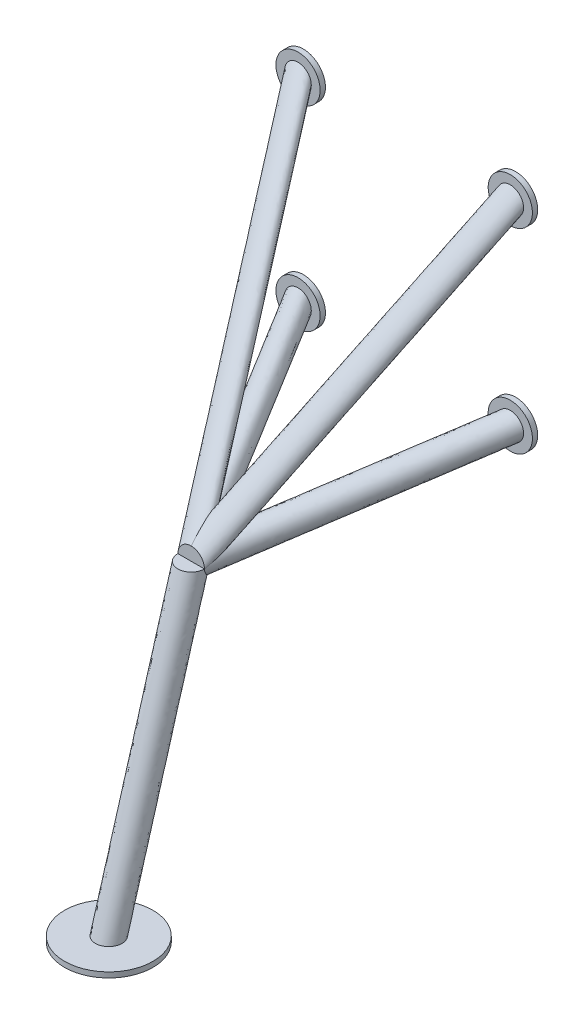
from build123d import *

# Parameters (mm, degrees)
BOSS_EXTRUDE2_START   = -444.5
SKETCH2_R             = 63.5
BOSS_EXTRUDE2_DEPTH   = 7.62
SKETCH1_R             = 31.75
BOSS_EXTRUDE1_DEPTH   = 7.62
BOSS_EXTRUDE1_2_DEPTH = 7.62
BOSS_EXTRUDE1_3_DEPTH = 7.62
BOSS_EXTRUDE1_4_DEPTH = 7.62
SKETCH4_R             = 19.05
SKETCH6_R             = 19.05
SKETCH7_R             = 19.05


with BuildPart() as part:
    # Sketch2 → Boss-Extrude2 (new body)
    with BuildSketch(Plane(origin=(0, 0, 0), x_dir=(1, 0, 0), z_dir=(0, 1, 0)).offset(BOSS_EXTRUDE2_START)):
        with Locations((191.834943245, -431.8)):
            Circle(SKETCH2_R)
    extrude(amount=BOSS_EXTRUDE2_DEPTH)

    # Sweep1: sweep along a path in Sketch3
    with BuildLine(Plane(origin=(191.834943245, 0, 0), x_dir=(0, 0, -1), z_dir=(1, 0, 0))) as sweep1_path:
        Line((-431.8, -436.88), (-313.492744217, -30.280470951))
    # Sketch4 → Sweep1 (sweep)
    with BuildSketch(Plane(origin=(0, -436.88, 0), x_dir=(1, 0, 0), z_dir=(0, 1, 0))):
        with Locations((191.834943245, -431.8)):
            Circle(SKETCH4_R)
    sweep(path=sweep1_path.line)



with BuildPart() as body_2:
    # Sketch1 → Boss-Extrude1 (new body)
    with BuildSketch(Plane.XY):
        with Locations((39.434943245, 61.582040816)):
            Circle(SKETCH1_R)
    extrude(amount=BOSS_EXTRUDE1_DEPTH)


with BuildPart() as body_3:
    # Sketch1 → Boss-Extrude1 2 (new body)
    with BuildSketch(Plane.XY):
        with Locations((39.434943245, 342.12244898)):
            Circle(SKETCH1_R)
    extrude(amount=BOSS_EXTRUDE1_2_DEPTH)


with BuildPart() as body_4:
    # Sketch1 → Boss-Extrude1 3 (new body)
    with BuildSketch(Plane.XY):
        with Locations((344.234943245, 342.12244898)):
            Circle(SKETCH1_R)
    extrude(amount=BOSS_EXTRUDE1_3_DEPTH)


with BuildPart() as body_5:
    # Sketch1 → Boss-Extrude1 4 (new body)
    with BuildSketch(Plane.XY):
        with Locations((344.234943245, 61.582040816)):
            Circle(SKETCH1_R)
    extrude(amount=BOSS_EXTRUDE1_4_DEPTH)


with BuildPart() as part_1:
    add(part.part)

    add(body_3.part)  # Sweep2 merges body 3
    # Sweep2: sweep along a curve in space
    with BuildLine() as sweep2_path:
        Line((39.434943245, 342.12244898, 7.62), (191.834943245, -30.280470951, 313.492744217))
    # Sketch6 → Sweep2 (sweep)
    with BuildSketch(Plane.XY.offset(7.62)):
        with Locations((39.434943245, 342.12244898)):
            Circle(SKETCH6_R)
    sweep2 = sweep(path=sweep2_path.line)


    add(body_2.part)  # Sweep3 merges body 2
    # Sweep3: sweep along a curve in space
    with BuildLine() as sweep3_path:
        Line((39.434943245, 61.582040816, 7.62), (191.834943245, -30.280470951, 313.492744217))
    # Sketch7 → Sweep3 (sweep)
    with BuildSketch(Plane.XY.offset(7.62)):
        with Locations((39.434943245, 61.582040816)):
            Circle(SKETCH7_R)
    sweep3 = sweep(path=sweep3_path.line)

    # Mirror1: Sweep2, Sweep3 across plane
    add(sweep2.mirror(Plane(origin=(191.834943245, 0, 0), x_dir=(0, 0, 1), z_dir=(1, 0, 0))))
    add(sweep3.mirror(Plane(origin=(191.834943245, 0, 0), x_dir=(0, 0, 1), z_dir=(1, 0, 0))))


solid = Compound([body_4.part, body_5.part, part_1.part])
